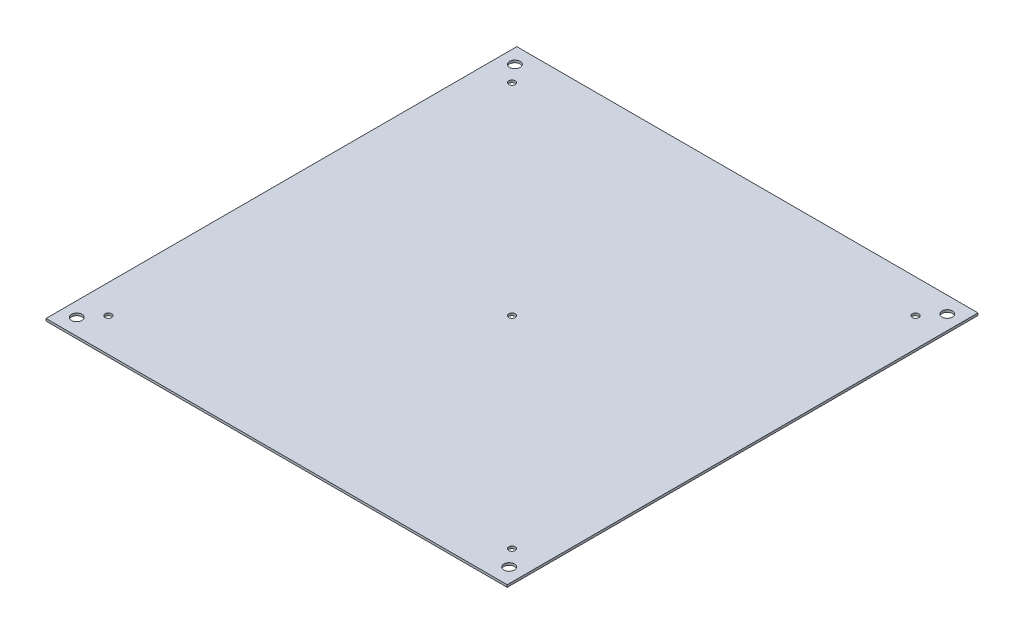
from build123d import *

# Parameters (mm, degrees)
SKETCH1_W            = 240
SKETCH1_H            = 245
BOSS_EXTRUDE1_DEPTH  = 1.2
M3_CLEARANCE_HOLE1_D = 3.4
M5_CLEARANCE_HOLE1_D = 5.5


with BuildPart() as part:
    # Sketch1 → Boss-Extrude1 (new body)
    with BuildSketch(Plane(origin=(0, 0, 0), x_dir=(1, 0, 0), z_dir=(0, 1, 0))):
        Rectangle(SKETCH1_W, SKETCH1_H)
    extrude(amount=BOSS_EXTRUDE1_DEPTH)

    # M3 Clearance Hole1 (through all)
    with Locations(Plane(origin=(0, 1.2, 0), x_dir=(1, 0, 0), z_dir=(0, 1, 0))):
        with Locations((0, 0), (105, 105), (-105, -105), (-105, 105), (105, -105)):
            Hole(M3_CLEARANCE_HOLE1_D / 2)

    # M5 Clearance Hole1 (through all)
    with Locations(Plane(origin=(0, 0, 0), x_dir=(-1, 0, 0), z_dir=(0, -1, 0))):
        with Locations((-112.5, -114), (112.5, 114), (112.5, -114), (-112.5, 114)):
            Hole(M5_CLEARANCE_HOLE1_D / 2)


solid = part.part
